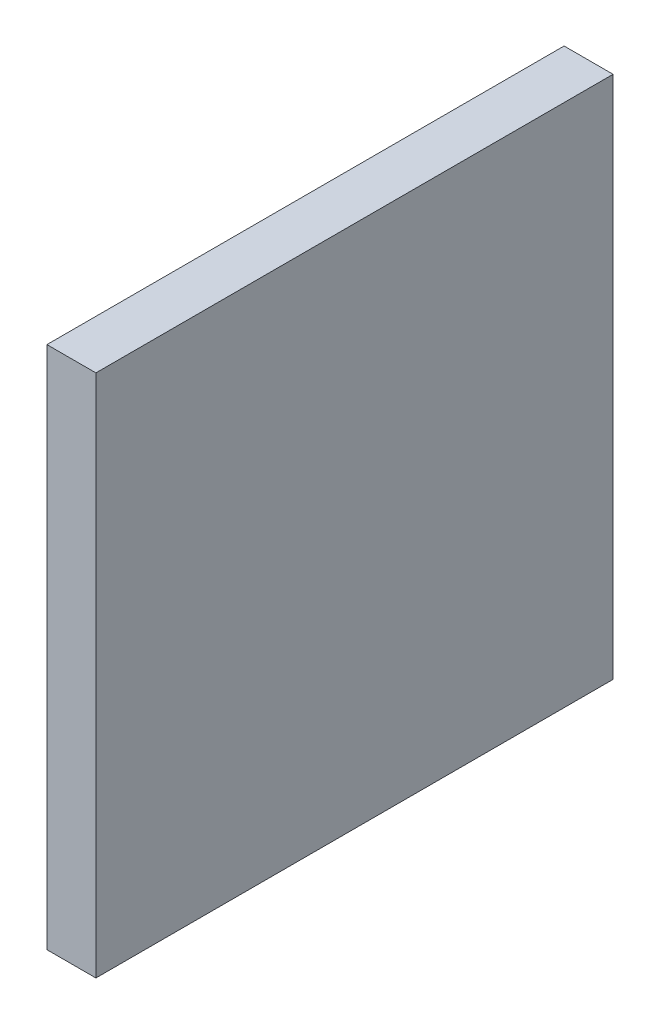
from build123d import *

# Parameters (mm, degrees)
SKETCH2_W           = 5
SKETCH2_H           = 53.502447605
BOSS_EXTRUDE1_DEPTH = 52.8


with BuildPart() as part:
    # Sketch2 → Boss-Extrude1 (new body)
    with BuildSketch(Plane.XY.offset(-331.8)):
        with Locations((-124.8, -26.751223803)):
            Rectangle(SKETCH2_W, SKETCH2_H)
    extrude(amount=BOSS_EXTRUDE1_DEPTH)


solid = part.part
